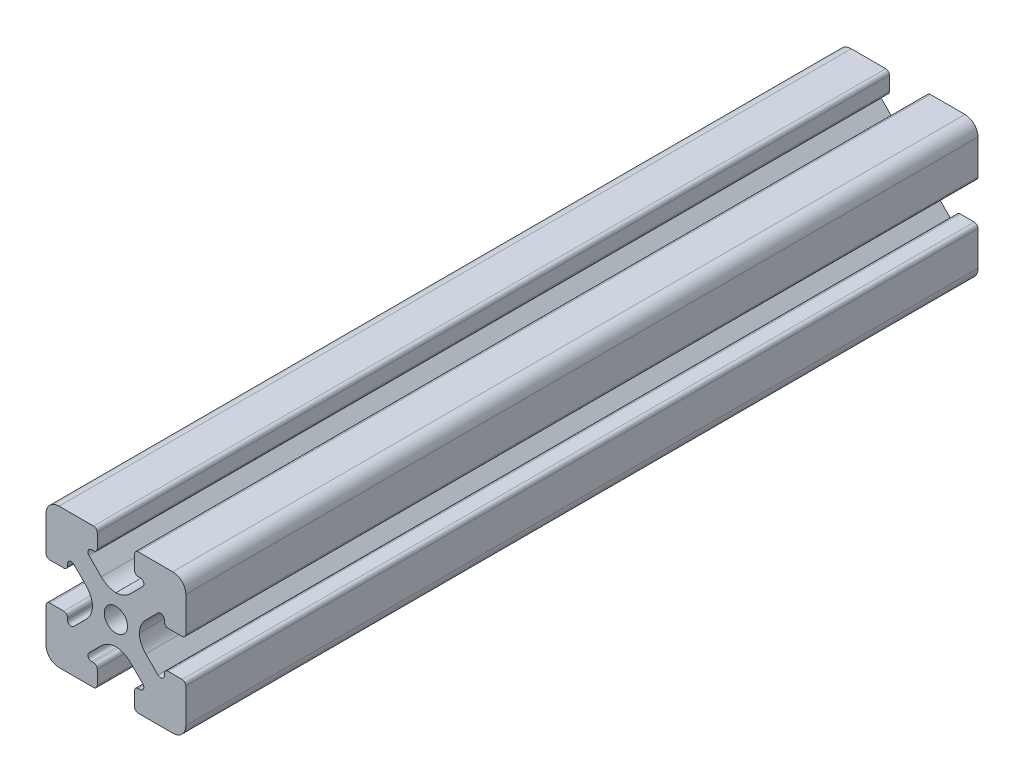
from build123d import *

# Parameters (mm, degrees)
BOSS_EXTRUDE1_DEPTH = 42.5


with BuildPart() as part:
    # Sketch4 → Boss-Extrude1 (new body, symmetric)
    with BuildSketch(Plane.XY):
        with BuildLine():
            Line((2.4, -7.5), (6.1, -7.5))
            ThreePointArc((6.1, -7.5), (7.089949494, -7.089949494), (7.5, -6.1))
            Line((7.5, -6.1), (7.5, -2.4))
            ThreePointArc((7.5, -2.4), (7.382842712, -2.117157288), (7.1, -2))
            Line((7.1, -2), (5.595331881, -2))
            ThreePointArc((5.595331881, -2), (5.312489168, -2.117157288), (5.195331881, -2.4))
            Line((5.195331881, -2.4), (5.195331881, -2.6))
            ThreePointArc((5.195331881, -2.6), (4.948405254, -2.969551813), (4.512489168, -2.882842712))
            Line((4.512489168, -2.882842712), (3.202943725, -1.57329727))
            ThreePointArc((3.202943725, -1.57329727), (2.682689122, -0.794681232), (2.5, 0.123759005))
            Line((2.5, 0.123759005), (2.5, 0))
            Line((2.5, 0), (1.25, 0))
            ThreePointArc((1.25, 0), (0.883883476, -0.883883476), (0, -1.25))
            Line((0, -1.25), (0, -2.5))
            Line((0, -2.5), (-0.123759005, -2.5))
            ThreePointArc((-0.123759005, -2.5), (0.794681232, -2.682689122), (1.57329727, -3.202943725))
            Line((1.57329727, -3.202943725), (2.882842712, -4.512489168))
            ThreePointArc((2.882842712, -4.512489168), (2.969551813, -4.948405254), (2.6, -5.195331881))
            Line((2.6, -5.195331881), (2.4, -5.195331881))
            ThreePointArc((2.4, -5.195331881), (2.117157288, -5.312489168), (2, -5.595331881))
            Line((2, -5.595331881), (2, -7.1))
            ThreePointArc((2, -7.1), (2.117157288, -7.382842712), (2.4, -7.5))
        make_face()
    extrude(amount=BOSS_EXTRUDE1_DEPTH, both=True)

    # Mirror1: part across plane


with BuildPart() as part_1:
    add(part.part)
    add(part.part.mirror(Plane(origin=(0, 0, 0), x_dir=(0, 0, 1), z_dir=(1, 0, 0))))

    # Mirror2: part across plane


with BuildPart() as part_2:
    add(part_1.part)
    add(part_1.part.mirror(Plane.ZX))


solid = part_2.part
